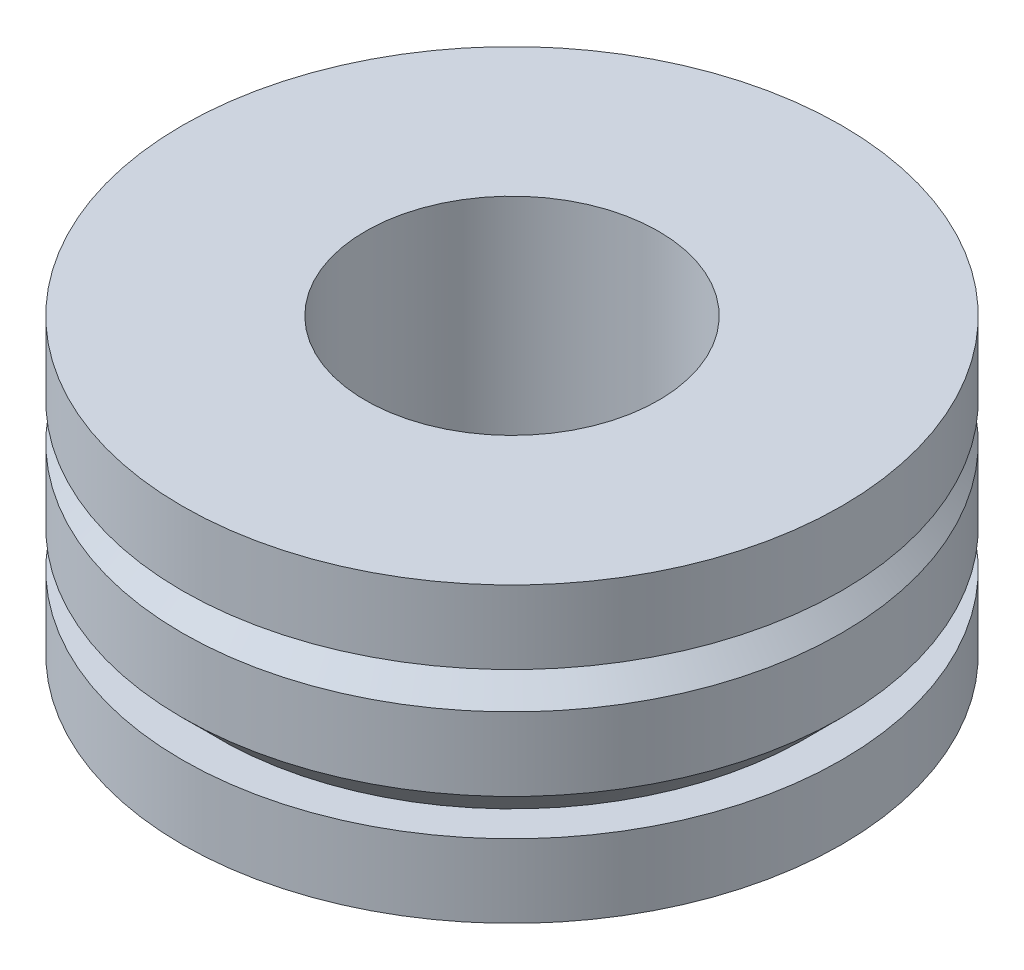
from build123d import *


with BuildPart() as part:
    # 草图1 → 旋转1 (revolve)
    with BuildSketch(Plane.XY):
        Polygon((-85.5, 4), (-88, 4), (-88, 0), (-85.5, 0), (-85.5, 1), (-86, 1), (-85.5, 1.5), (-85.5, 2.5), (-86, 3), (-85.5, 3), align=None)
    revolve(axis=Axis((-90, 4, 0), (0, -1, 0)))


solid = part.part
